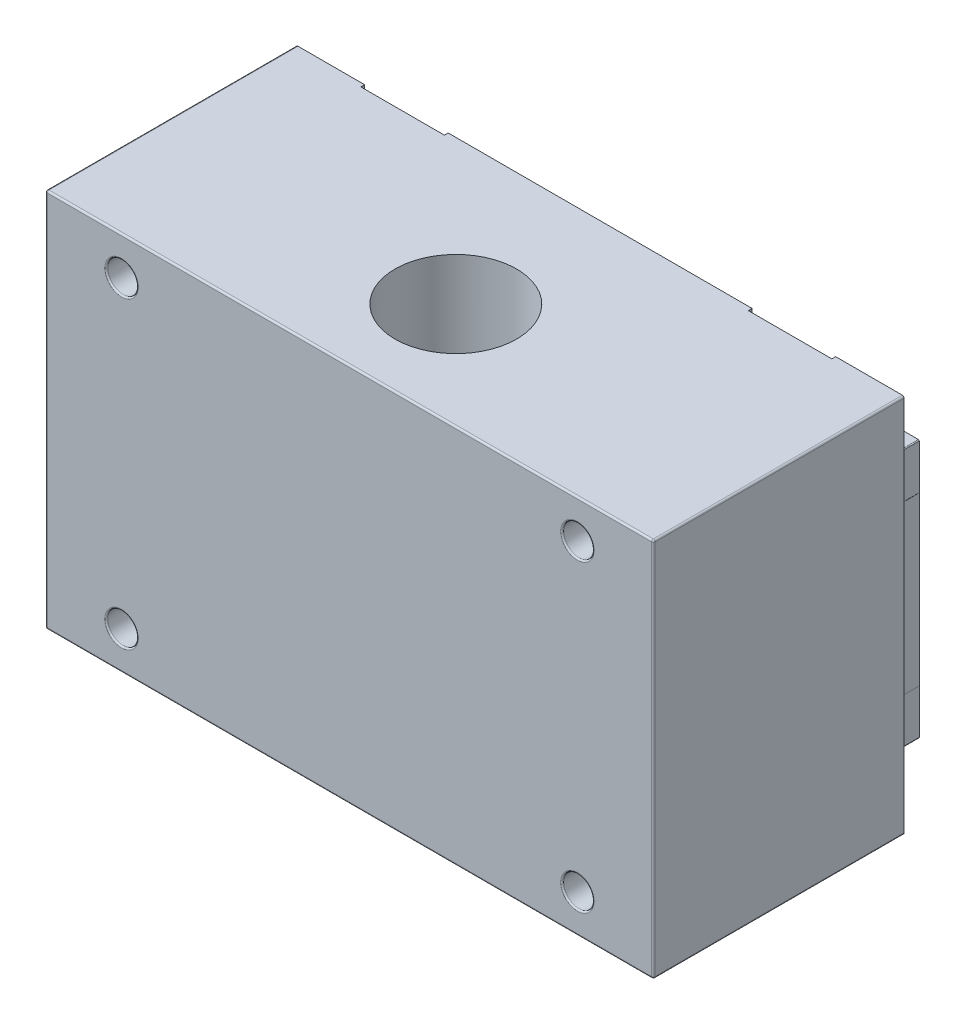
from build123d import *

# Parameters (mm, degrees)
EXTRUDE_1_DEPTH     = 6
EXTRUDE_1_2_DEPTH   = 6
EXTRUDE_2_DEPTH     = 22
EXTRUDE_3_DEPTH     = 6
FILLET_1_R          = 0.2
FILLET_2_R          = 0.12
FILLET_3_R          = 0.36
FILLET_4_R          = 0.2
FILLET_5_R          = 0.12
FILLET_6_R          = 0.36
EXTRUDE_12_DEPTH    = 8
EXTRUDE_13_DEPTH    = 8
EXTRUDE_14_DEPTH    = 34
SKETCH_7_R          = 8
CUT_EXTRUDE_1_DEPTH = 50
SKETCH_8_R          = 10
CUT_EXTRUDE_2_DEPTH = 5
SKETCH_9_R          = 9.761392529
SKETCH_9_R_2        = 8.01
EXTRUDE_16_DEPTH    = 4.77
SKETCH_10_R         = 2
CUT_EXTRUDE_3_DEPTH = 5
FILLET_7_R          = 0.2
FILLET_8_R          = 0.23


with BuildPart() as part:
    # 草图1 → 凸台-拉伸1 (new body)
    with BuildSketch(Plane(origin=(0, 0, 0), x_dir=(1, 0, 0), z_dir=(0, 1, 0))):
        Polygon((0, 0), (7, 0), (7, -4.5), (18, -4.5), (18, 0), (25, 0), (25, -9), (0, -9), align=None)
    extrude(amount=EXTRUDE_1_DEPTH)



with BuildPart() as body_2:
    # 草图1 → Extrude 1 2 (new body)
    with BuildSketch(Plane(origin=(0, 0, 0), x_dir=(1, 0, 0), z_dir=(0, 1, 0))):
        Polygon((51, 0), (51, -9), (76, -9), (76, 0), (69, 0), (69, -4.5), (58, -4.5), (58, 0), align=None)
    extrude(amount=EXTRUDE_1_2_DEPTH)


with BuildPart() as part_1:
    add(part.part)

    add(body_2.part)  # 凸台-拉伸2 merges body 2
    # 草图2 → 凸台-拉伸2 (add)
    with BuildSketch(Plane(origin=(0, 6, 0), x_dir=(1, 0, 0), z_dir=(0, 1, 0))):
        Polygon((7, 0), (-0.02, 0), (-0.02, -10), (25.02, -10), (25.02, 0), (18, 0), (18, -4.5), (7, -4.5), align=None)
        Polygon((58, 0), (50.98, 0), (50.98, -10), (76.02, -10), (76.02, 0), (69, 0), (69, -4.5), (58, -4.5), align=None)
    extrude(amount=EXTRUDE_2_DEPTH)

    # 草图3 → 凸台-拉伸3 (add)
    with BuildSketch(Plane(origin=(0, 28, 0), x_dir=(1, 0, 0), z_dir=(0, 1, 0))):
        Polygon((7, 0), (0, 0), (0, -9), (25, -9), (25, 0), (18, 0), (18, -4.5), (7, -4.5), align=None)
        Polygon((58, 0), (51, 0), (51, -9), (76, -9), (76, 0), (69, 0), (69, -4.5), (58, -4.5), align=None)
    extrude(amount=EXTRUDE_3_DEPTH)

    # 圆角1
    fillet_1_edges = [part_1.edges().sort_by_distance(p)[0] for p in [
        (25, 3, 9),
        (0, 3, 9),
        (0, 31, 9),
        (25, 31, 9),
    ]]
    fillet(fillet_1_edges, radius=FILLET_1_R)

    # 圆角2
    fillet_2_edges = [part_1.edges().sort_by_distance(p)[0] for p in [
        (0.058578644, 34, 8.941421356),
        (24.941421356, 34, 8.941421356),
        (0, 0, 4.4),
        (0, 34, 4.4),
        (25, 0, 4.4),
        (12.5, 0, 9),
        (0.058578644, 0, 8.941421356),
        (24.941421356, 0, 8.941421356),
        (25, 34, 4.4),
        (12.5, 34, 9),
    ]]
    fillet(fillet_2_edges, radius=FILLET_2_R)

    # 圆角3
    fillet_3_edges = [part_1.edges().sort_by_distance(p)[0] for p in [
        (-0.02, 17, 10),
        (25.02, 17, 10),
    ]]
    fillet(fillet_3_edges, radius=FILLET_3_R)

    # 圆角4
    fillet_4_edges = [part_1.edges().sort_by_distance(p)[0] for p in [
        (51, 31, 9),
        (76, 31, 9),
        (76, 3, 9),
        (51, 3, 9),
    ]]
    fillet(fillet_4_edges, radius=FILLET_4_R)

    # 圆角5
    fillet_5_edges = [part_1.edges().sort_by_distance(p)[0] for p in [
        (51, 34, 4.4),
        (51, 0, 4.4),
        (76, 0, 4.4),
        (63.5, 0, 9),
        (51.058578644, 0, 8.941421356),
        (75.941421356, 0, 8.941421356),
        (63.5, 34, 9),
        (76, 34, 4.4),
        (75.941421356, 34, 8.941421356),
        (51.058578644, 34, 8.941421356),
    ]]
    fillet(fillet_5_edges, radius=FILLET_5_R)

    # 圆角6
    fillet_6_edges = [part_1.edges().sort_by_distance(p)[0] for p in [
        (50.98, 17, 10),
        (76.02, 17, 10),
    ]]
    fillet(fillet_6_edges, radius=FILLET_6_R)

    # 草图4 → 凸台-拉伸12 (add)
    with BuildSketch(Plane(origin=(0, -8, 0), x_dir=(-1, 0, 0), z_dir=(0, -1, 0))):
        Polygon((-7, -4.5), (-7, -4), (2, -4), (2, -37), (-78, -37), (-78, -4), (-69, -4), (-69, -4.5), (-58, -4.5), (-58, -4), (-18, -4), (-18, -4.5), align=None)
    extrude(amount=-EXTRUDE_12_DEPTH)

    # 草图5 → 凸台-拉伸13 (add)
    with BuildSketch(Plane(origin=(0, 34, 0), x_dir=(1, 0, 0), z_dir=(0, 1, 0))):
        Polygon((7, -4), (7, -4.5), (18, -4.5), (18, -4), (58, -4), (58, -4.5), (69, -4.5), (69, -4), (78, -4), (78, -37), (-2, -37), (-2, -4), align=None)
    extrude(amount=EXTRUDE_13_DEPTH)

    # 草图6 → 凸台-拉伸14 (add)
    with BuildSketch(Plane(origin=(0, 0, 0), x_dir=(1, 0, 0), z_dir=(0, 1, 0))):
        Polygon((0, -4.5), (-2, -4.5), (-2, -37), (78, -37), (78, -4), (76, -4), (76, -10.000963712), (0, -10.000963712), align=None)
    extrude(amount=EXTRUDE_14_DEPTH)

    # 草图7 → 切除-拉伸1 (cut)
    with BuildSketch(Plane(origin=(0, 42, 0), x_dir=(1, 0, 0), z_dir=(0, 1, 0))):
        with Locations((38, -23)):
            Circle(SKETCH_7_R)
    extrude(amount=-CUT_EXTRUDE_1_DEPTH, mode=Mode.SUBTRACT)

    # 草图8 → 切除-拉伸2 (cut)
    with BuildSketch(Plane.XZ.offset(8)):
        with Locations((38, 23)):
            Circle(SKETCH_8_R)
    extrude(amount=-CUT_EXTRUDE_2_DEPTH, mode=Mode.SUBTRACT)

    # 草图9 → 凸台-拉伸16 (add)
    with BuildSketch(Plane.XZ.offset(3)):
        with Locations((38, 23)):
            Circle(SKETCH_9_R)
        with Locations((38, 23)):
            Circle(SKETCH_9_R_2, mode=Mode.SUBTRACT)
    extrude(amount=EXTRUDE_16_DEPTH)

    # 草图10 → 切除-拉伸3 (cut)
    with BuildSketch(Plane.XY.offset(37)):
        with Locations((8, 37)):
            Circle(SKETCH_10_R)
        with Locations((8, -3)):
            Circle(SKETCH_10_R)
        with Locations((68, -3)):
            Circle(SKETCH_10_R)
        with Locations((68, 37)):
            Circle(SKETCH_10_R)
    extrude(amount=-CUT_EXTRUDE_3_DEPTH, mode=Mode.SUBTRACT)

    # 圆角7
    fillet_7_edges = [part_1.edges().sort_by_distance(p)[0] for p in [
        (66, 37, 37),
        (66, -3, 37),
        (6, -3, 37),
        (6, 37, 37),
    ]]
    fillet(fillet_7_edges, radius=FILLET_7_R)

    # 圆角8
    fillet_8_edges = [part_1.edges().sort_by_distance(p)[0] for p in [
        (-2, 17, 37),
        (78, 17, 37),
        (78, -8, 20.5),
        (38, -8, 37),
        (-2, -8, 20.5),
        (-2, 42, 20.5),
        (38, 42, 37),
        (78, 42, 20.5),
    ]]
    fillet(fillet_8_edges, radius=FILLET_8_R)


solid = part_1.part
